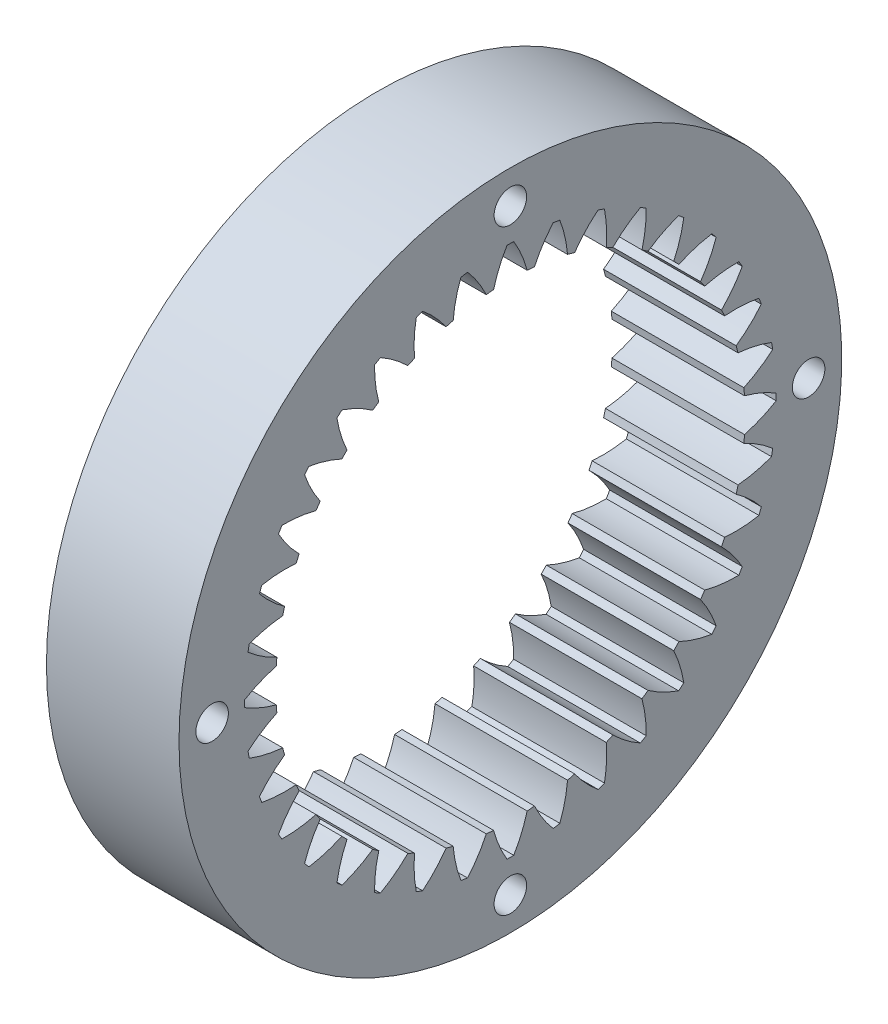
from build123d import *

# Parameters (mm, degrees)
BASPROSKE_W        = 12
BASPROSKE_H        = 8.75
TOOTHCUT_DEPTH     = 45.09081537
TEETHCUTS_COUNT    = 36
TEETHCUTS_ANGLE    = 350
SKETCH1_R          = 1.4732
CUT_EXTRUDE1_DEPTH = 45.09081537
CIRPATTERN1_COUNT  = 4


with BuildPart() as part:
    # BasProSke → Base-Revolve (revolve)
    with BuildSketch(Plane(origin=(0, 0, 0), x_dir=(1, 0, 0), z_dir=(0, 1, 0))):
        with Locations((6, 25.625)):
            Rectangle(BASPROSKE_W, BASPROSKE_H)
    revolve(axis=Axis((-10, 0, 0), (1, 0, 0)))

    # TooCutSke → ToothCut (cut, through all)
    with BuildSketch(Plane(origin=(0, 0, 0), x_dir=(0, 0, -1), z_dir=(1, 0, 0))):
        with BuildLine():
            ThreePointArc((1.526741109, 21.169617539), (1.017792977, 22.658366355), (0.306126421, 24.061552711))
            ThreePointArc((0.306126421, 24.061552711), (0, 24.0635), (-0.306126421, 24.061552711))
            ThreePointArc((-0.306126421, 24.061552711), (-1.017792977, 22.658366355), (-1.526741109, 21.169617539))
            ThreePointArc((-1.526741109, 21.169617539), (0, 21.2246), (1.526741109, 21.169617539))
        make_face()
    toothcut = extrude(amount=TOOTHCUT_DEPTH, mode=Mode.SUBTRACT)

    # TeethCuts: ToothCut ×36 about axis
    teethcuts_axis = Axis((-10, 0, 0), (1, 0, 0))
    for i in range(1, TEETHCUTS_COUNT):
        add(toothcut.rotate(teethcuts_axis, i * TEETHCUTS_ANGLE / (TEETHCUTS_COUNT - 1)), mode=Mode.SUBTRACT)

    # Sketch1 → Cut-Extrude1 (cut, through all)
    with BuildSketch(Plane(origin=(12, 0, 0), x_dir=(0, 0, -1), z_dir=(1, 0, 0))):
        with Locations((0, 27)):
            Circle(SKETCH1_R)
    cut_extrude1 = extrude(amount=-CUT_EXTRUDE1_DEPTH, mode=Mode.SUBTRACT)

    # CirPattern1: Cut-Extrude1 ×4 about axis
    cirpattern1_axis = Axis((72.068406294, 0, 0), (-1, 0, 0))
    for i in range(1, CIRPATTERN1_COUNT):
        add(cut_extrude1.rotate(cirpattern1_axis, i * 360 / CIRPATTERN1_COUNT), mode=Mode.SUBTRACT)


solid = part.part
